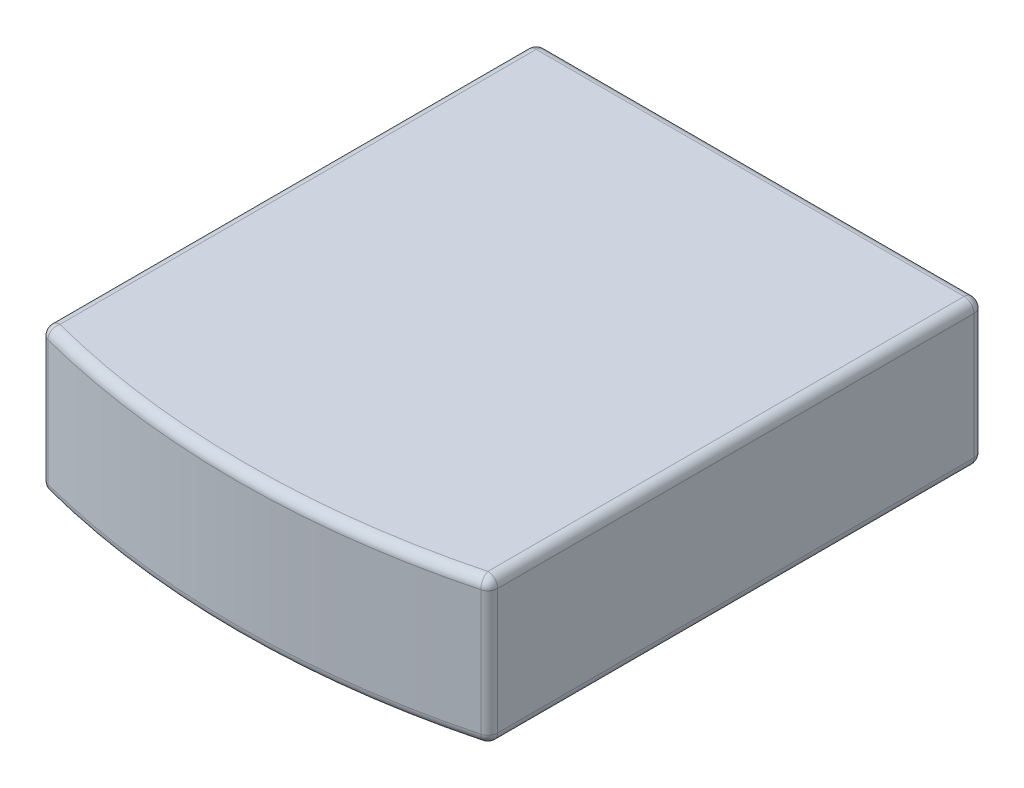
from build123d import *

# Parameters (mm, degrees)
SKETCH1_W           = 6.8
SKETCH1_H           = 2.2
BOSS_EXTRUDE1_DEPTH = 8
CUT_EXTRUDE1_DEPTH  = 8
FILLET1_R           = 0.15


with BuildPart() as part:
    # Sketch1 → Boss-Extrude1 (new body)
    with BuildSketch(Plane.XY):
        Rectangle(SKETCH1_W, SKETCH1_H)
    extrude(amount=BOSS_EXTRUDE1_DEPTH)

    # Sketch2 → Cut-Extrude1 (cut)
    with BuildSketch(Plane(origin=(0, 1.1, 0), x_dir=(1, 0, 0), z_dir=(0, 1, 0))):
        with BuildLine():
            Line((-3.4, -7.5), (-4.338442441, -8.7499714))
            Line((-4.338442441, -8.7499714), (5.303990533, -8.971786502))
            Line((5.303990533, -8.971786502), (3.4, -7.5))
            ThreePointArc((3.4, -7.5), (0, -7.952490287), (-3.4, -7.5))
        make_face()
    extrude(amount=-CUT_EXTRUDE1_DEPTH, mode=Mode.SUBTRACT)

    # Fillet1
    fillet1_edges = [part.edges().sort_by_distance(p)[0] for p in [
        (-3.4, 1.1, 3.75),
        (3.4, 1.1, 3.75),
        (3.4, -1.1, 3.75),
        (-3.4, -1.1, 3.75),
        (0, -1.1, 7.952490287),
        (-3.4, 0, 7.5),
        (0, 1.1, 7.952490287),
        (3.4, 0, 7.5),
        (0, 1.1, 0),
        (3.4, 0, 0),
        (0, -1.1, 0),
        (-3.4, 0, 0),
    ]]
    fillet(fillet1_edges, radius=FILLET1_R)


solid = part.part
